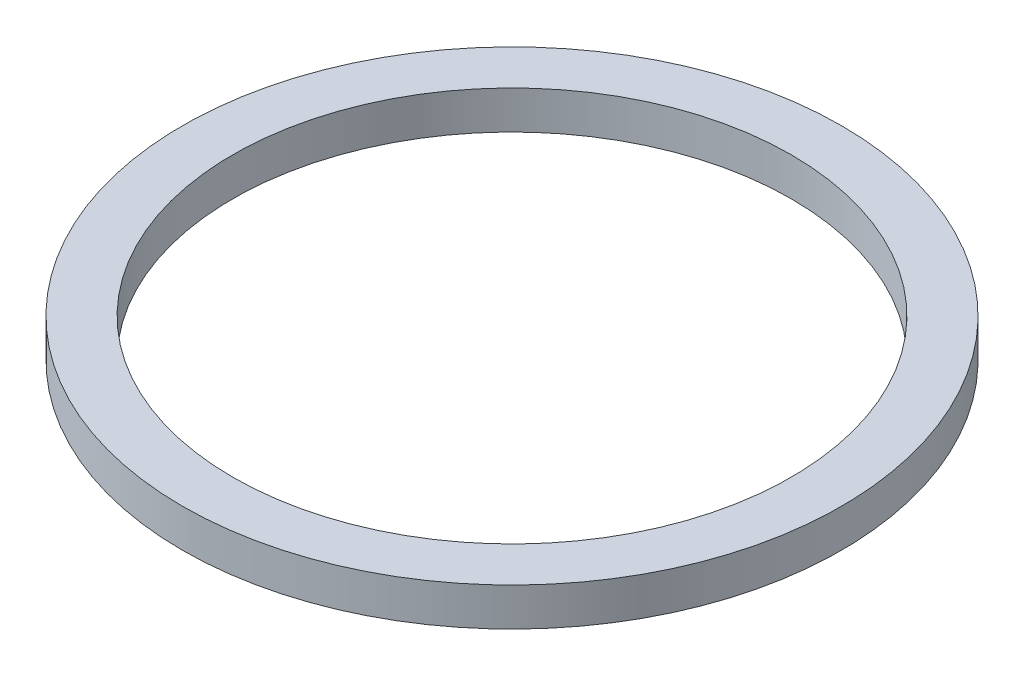
from build123d import *

# Parameters (mm, degrees)
SKETCH1_R           = 9.5
BOSS_EXTRUDE1_DEPTH = 1.1
SKETCH2_R           = 8.05
CUT_EXTRUDE1_DEPTH  = 2.1


with BuildPart() as part:
    # Sketch1 → Boss-Extrude1 (new body)
    with BuildSketch(Plane(origin=(0, 0, 0), x_dir=(1, 0, 0), z_dir=(0, 1, 0))):
        Circle(SKETCH1_R)
    extrude(amount=BOSS_EXTRUDE1_DEPTH)

    # Sketch2 → Cut-Extrude1 (cut, through all)
    with BuildSketch(Plane(origin=(0, 1.1, 0), x_dir=(1, 0, 0), z_dir=(0, 1, 0))):
        Circle(SKETCH2_R)
    extrude(amount=-CUT_EXTRUDE1_DEPTH, mode=Mode.SUBTRACT)


solid = part.part
